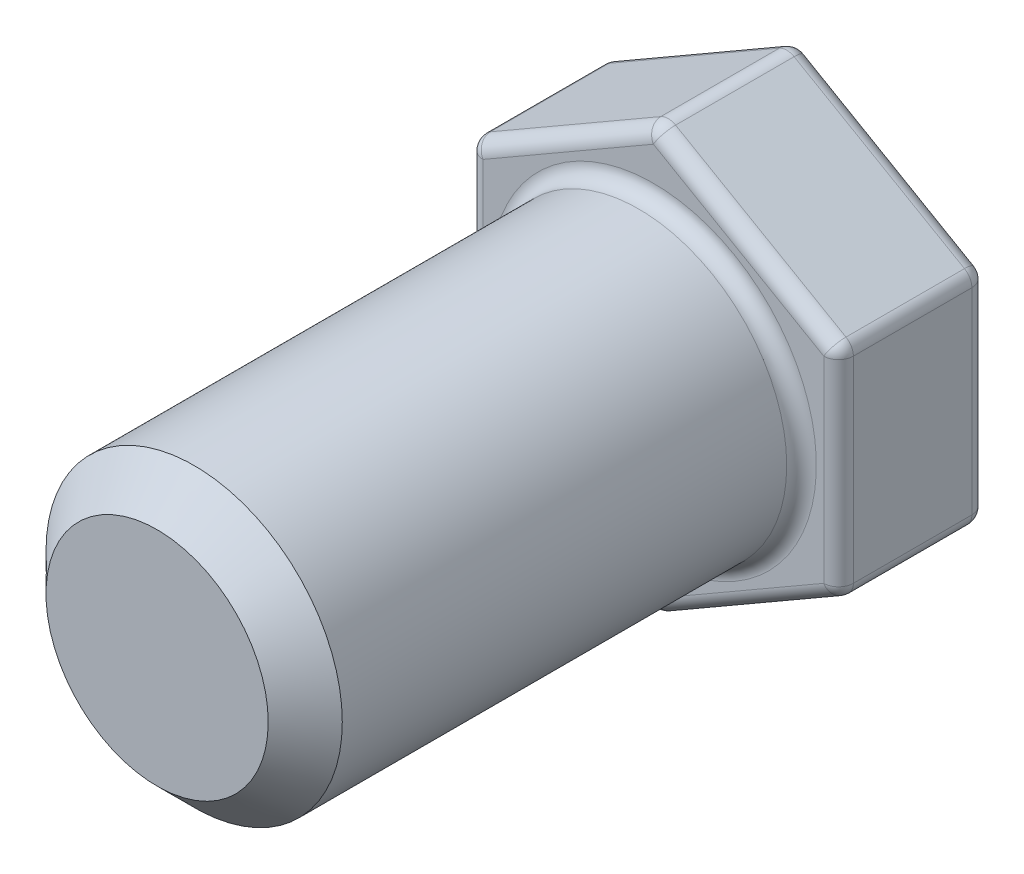
from build123d import *

# Parameters (mm, degrees)
SKETCH1_R           = 2
BOSS_EXTRUDE1_DEPTH = 6.7
BOSS_EXTRUDE2_DEPTH = 2
FILLET1_R           = 0.2
FILLET2_R           = 0.2
CHAMFER1_SIZE       = 0.5


with BuildPart() as part:
    # Sketch1 → Boss-Extrude1 (new body)
    with BuildSketch(Plane.XY):
        Circle(SKETCH1_R)
    extrude(amount=BOSS_EXTRUDE1_DEPTH)

    # Sketch2 → Boss-Extrude2 (add)
    with BuildSketch(Plane(origin=(0, 0, 0), x_dir=(-1, 0, 0), z_dir=(0, 0, -1))):
        Polygon((-2.5, 1.443375673), (-2.5, -1.443375673), (0, -2.886751346), (2.5, -1.443375673), (2.5, 1.443375673), (0, 2.886751346), align=None)
    extrude(amount=BOSS_EXTRUDE2_DEPTH)

    # Fillet1
    fillet1_edges = [part.edges().sort_by_distance(p)[0] for p in [
        (-2, 0, 0),
        (1.25, 2.165063509, 0),
        (2.5, 0, 0),
        (1.25, -2.165063509, 0),
        (-1.25, -2.165063509, 0),
        (-2.5, 0, 0),
        (-1.25, 2.165063509, 0),
        (1.25, 2.165063509, -2),
        (2.5, 0, -2),
        (1.25, -2.165063509, -2),
        (-1.25, -2.165063509, -2),
        (-2.5, 0, -2),
        (-1.25, 2.165063509, -2),
    ]]
    fillet(fillet1_edges, radius=FILLET1_R)

    # Fillet2
    fillet2_edges = [part.edges().sort_by_distance(p)[0] for p in [
        (0, 2.886751346, -1),
        (-2.5, 1.443375673, -1),
        (-2.5, -1.443375673, -1),
        (0, -2.886751346, -1),
        (2.5, -1.443375673, -1),
        (2.5, 1.443375673, -1),
        (0, -2.813180543, -1.94637683),
        (2.436285816, -1.406590271, -1.94637683),
        (-2.436285816, -1.406590271, -1.94637683),
        (2.436285816, 1.406590271, -1.94637683),
        (-2.436285816, 1.406590271, -1.94637683),
        (0, 2.813180543, -1.94637683),
        (-2.436285816, 1.406590271, -0.05362317),
        (-2.436285816, -1.406590271, -0.05362317),
        (0, 2.813180543, -0.05362317),
        (0, -2.813180543, -0.05362317),
        (2.436285816, 1.406590271, -0.05362317),
        (2.436285816, -1.406590271, -0.05362317),
    ]]
    fillet(fillet2_edges, radius=FILLET2_R)

    # Chamfer1
    chamfer1_edges = [part.edges().sort_by_distance(p)[0] for p in [
        (-2, 0, 6.7),
    ]]
    chamfer(chamfer1_edges, length=CHAMFER1_SIZE)


solid = part.part
